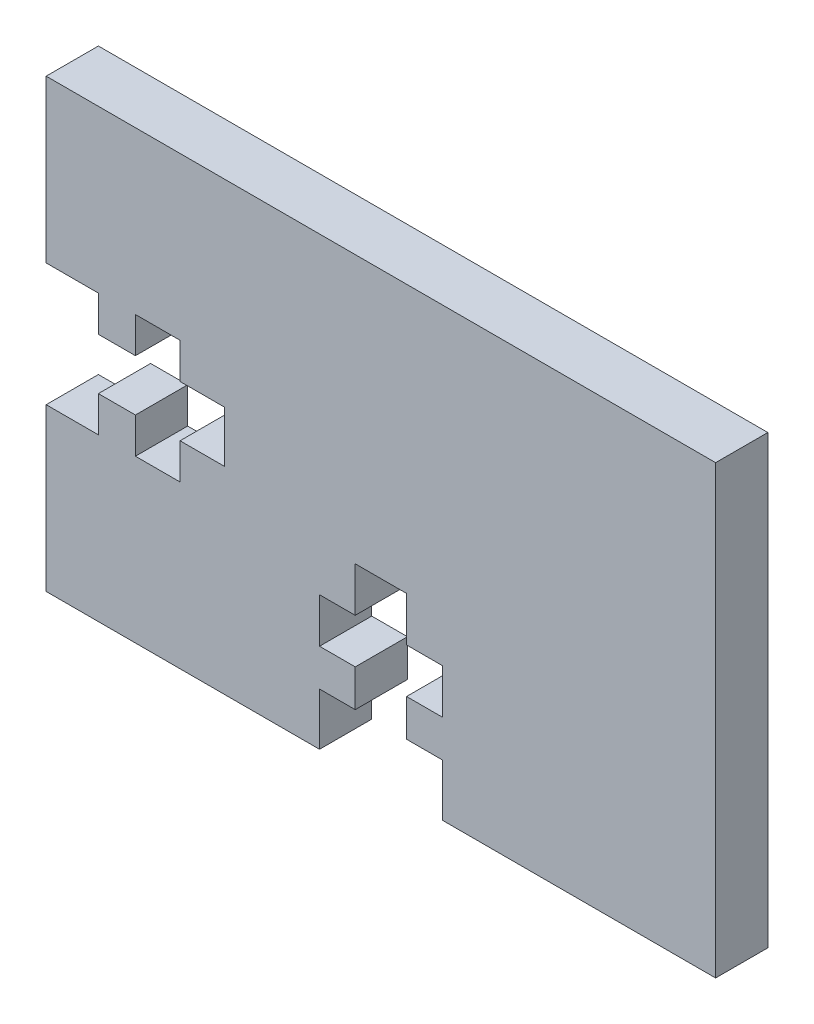
from build123d import *

# Parameters (mm, degrees)
BOSS_EXTRUDE1_DEPTH = 2.9718


with BuildPart() as part:
    # Sketch1 → Boss-Extrude1 (new body)
    with BuildSketch(Plane.XY):
        Polygon((2.9718, 14.1605), (5.08, 14.1605), (5.08, 16.1925), (7.62, 16.1925), (7.62, 14.1605), (10.16, 14.1605), (10.16, 11.2395), (7.62, 11.2395), (7.62, 9.2075), (5.08, 9.2075), (5.08, 11.2395), (2.9718, 11.2395), (2.9718, 9.2075), (0, 9.2075), (0, 0), (15.5575, 0), (15.5575, 2.9718), (17.5895, 2.9718), (17.5895, 5.08), (15.5575, 5.08), (15.5575, 7.62), (17.5895, 7.62), (17.5895, 10.16), (20.5105, 10.16), (20.5105, 7.62), (22.5425, 7.62), (22.5425, 5.08), (20.5105, 5.08), (20.5105, 2.9718), (22.5425, 2.9718), (22.5425, 0), (38.1, 0), (38.1, 25.4), (0, 25.4), (0, 16.1925), (2.9718, 16.1925), align=None)
    extrude(amount=BOSS_EXTRUDE1_DEPTH)


solid = part.part
